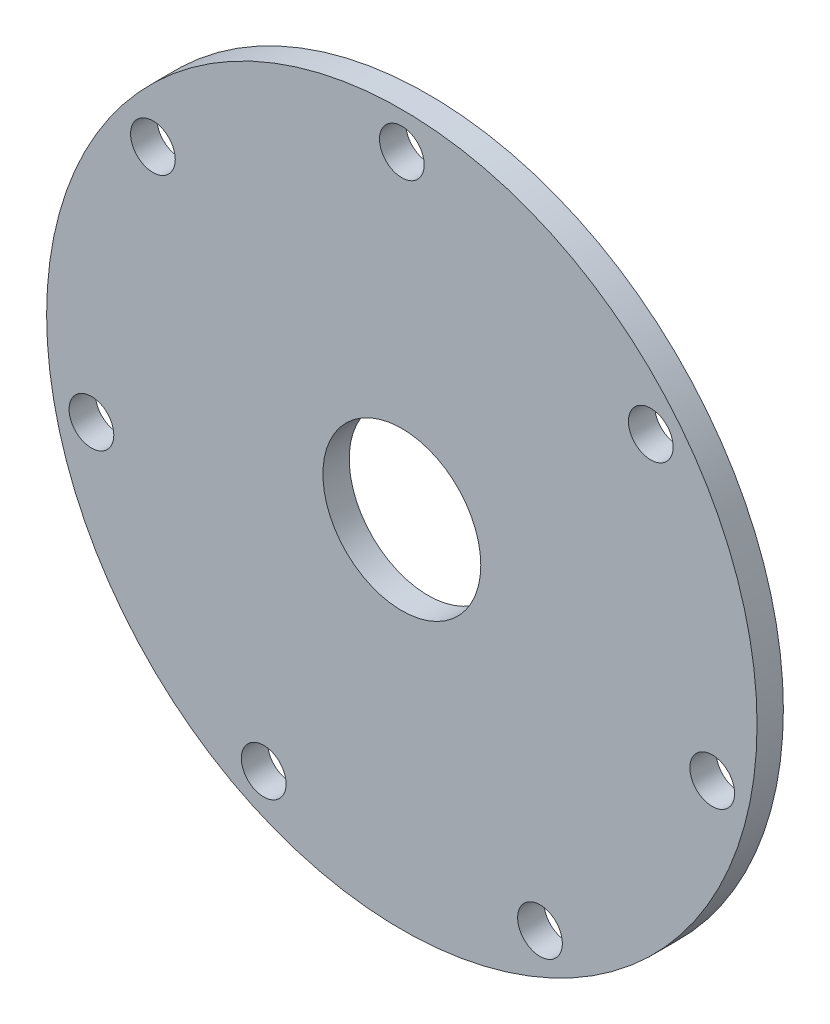
from build123d import *

# Parameters (mm, degrees)
ESQUISSE1_R        = 67.5
ESQUISSE1_R_2      = 4.25
ESQUISSE1_R_3      = 15
BOSS_EXTRU_1_DEPTH = 5


with BuildPart() as part:
    # Esquisse1 → Boss.-Extru.1 (new body)
    with BuildSketch(Plane.XY):
        Circle(ESQUISSE1_R)
        with Locations((0, 60.5)):
            Circle(ESQUISSE1_R_2, mode=Mode.SUBTRACT)
        with Locations((47.300804689, 37.721133012)):
            Circle(ESQUISSE1_R_2, mode=Mode.SUBTRACT)
        with Locations((58.983138687, -13.462516504)):
            Circle(ESQUISSE1_R_2, mode=Mode.SUBTRACT)
        with Locations((26.249966217, -54.508616508)):
            Circle(ESQUISSE1_R_2, mode=Mode.SUBTRACT)
        with Locations((-26.249966217, -54.508616508)):
            Circle(ESQUISSE1_R_2, mode=Mode.SUBTRACT)
        with Locations((-58.983138687, -13.462516504)):
            Circle(ESQUISSE1_R_2, mode=Mode.SUBTRACT)
        with Locations((-47.300804689, 37.721133012)):
            Circle(ESQUISSE1_R_2, mode=Mode.SUBTRACT)
        Circle(ESQUISSE1_R_3, mode=Mode.SUBTRACT)
    extrude(amount=BOSS_EXTRU_1_DEPTH)


solid = part.part
